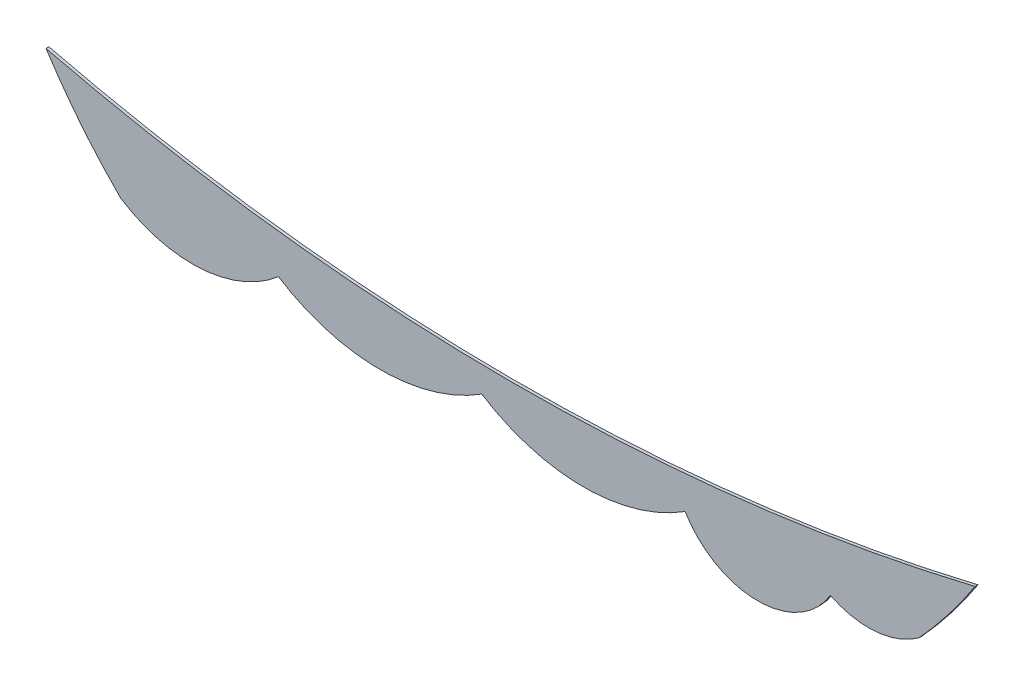
from build123d import *

# Parameters (mm, degrees)
SALIENTE_EXTRUIR1_DEPTH = 0.1


with BuildPart() as part:
    # Model → Saliente-Extruir1 (new body)
    with BuildSketch(Plane.XY):
        with BuildLine():
            ThreePointArc((21.476433387, 16.588313555), (24.254914005, 15.868770802), (26.909424151, 16.960224971))
            ThreePointArc((26.909424151, 16.960224971), (30.409424151, 15.941022565), (33.909424151, 16.960224971))
            ThreePointArc((33.909424151, 16.960224971), (37.409424151, 15.941022565), (40.909424151, 16.960224971))
            ThreePointArc((40.909424151, 16.960224971), (43.409424151, 15.544749023), (45.909424151, 16.960224971))
            ThreePointArc((45.909424151, 16.960224971), (47.473571512, 16.662305343), (48.963743034, 17.223288326))
            ThreePointArc((48.963743034, 17.223288326), (49.978796563, 18.429539819), (50.890575849, 19.715632689))
            ThreePointArc((50.890575849, 19.715632689), (34.89707312, 17.835221297), (18.909424151, 19.764769681))
            ThreePointArc((18.909424151, 19.764769681), (20.10751204, 18.107513266), (21.476433387, 16.588313555))
        make_face()
    extrude(amount=SALIENTE_EXTRUIR1_DEPTH)


solid = part.part
